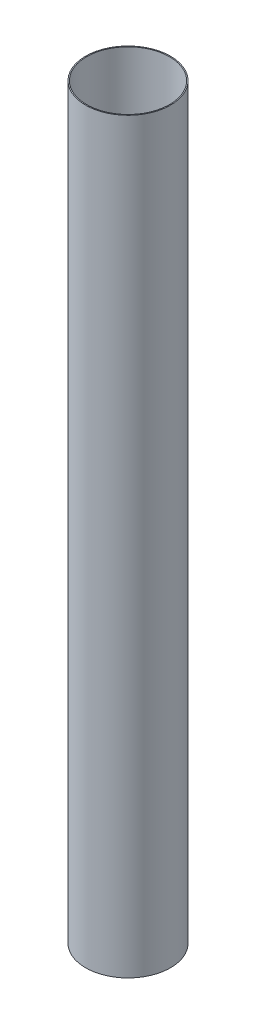
from build123d import *

# Parameters (mm, degrees)
SKETCH1_W = 0.4572
SKETCH1_H = 342.9


with BuildPart() as part:
    # Sketch1 → Revolve1 (revolve)
    with BuildSketch(Plane.XY):
        with Locations((19.2659, 171.45)):
            Rectangle(SKETCH1_W, SKETCH1_H)
    revolve(axis=Axis((0, -13.97, 0), (0, 1, 0)))


solid = part.part
